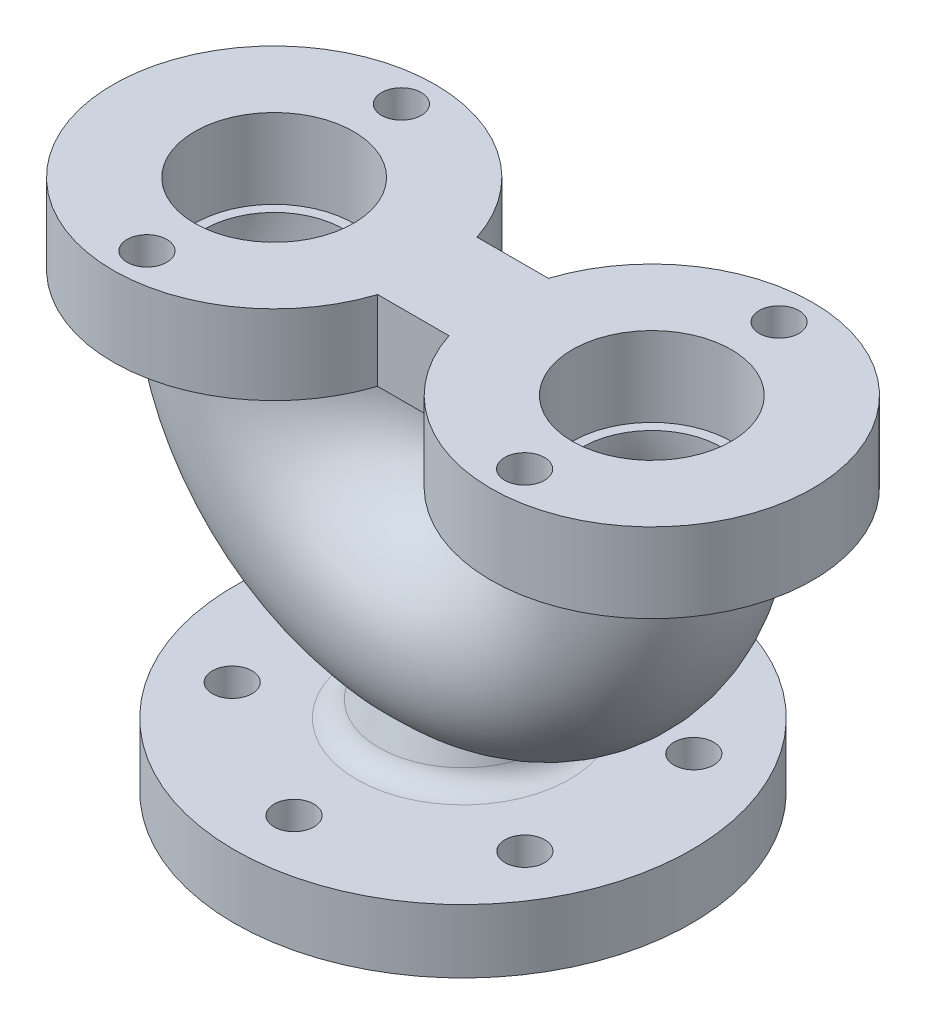
from build123d import *
from build123d.topology import SkipClean

# Parameters (mm, degrees)
SKETCH1_R           = 9.999999999999991
SKETCH1_R_2         = 10.000000000000009
BOSS_EXTRUDE1_DEPTH = 32
REVOLVE1_ANGLE      = 180.0000000000004
FILLET1_R           = 12
SKETCH4_R           = 50.000000000000014
SKETCH4_R_2         = 35.00000000000001
SKETCH7_R           = 40.00000000000001
BOSS_EXTRUDE2_DEPTH = 40
SKETCH9_R           = 9.999999999999996
SKETCH9_R_2         = 9.999999999999995
CUT_EXTRUDE1_DEPTH  = 40


with BuildPart() as part:
    # Sketch1 → Boss-Extrude1 (new body)
    with BuildSketch(Plane(origin=(0, 0, 0), x_dir=(1, 0, 0), z_dir=(0, 1, 0))):
        with BuildLine():
            Line((0, 20), (0, 0))
            ThreePointArc((4.961e-14, -1.421e-14), (115.00000000000001, 115.00000000000001), (0, 230))
            Line((0, 229.99999999999997), (0, 209.99999999999997))
            ThreePointArc((3.4e-16, 209.99999999999997), (10.000000000000608, 199.99999999999994), (0, 189.99999999999991))
            Line((0, 189.99999999999991), (0, 40))
            ThreePointArc((3.4e-16, 40), (10.000000000000004, 30), (0, 20))
        make_face()
        with Locations(Location((73.61215932167678, 72.49999999999912, 0), (0, 0, 270))):
            Circle(SKETCH1_R, mode=Mode.SUBTRACT)
        with Locations(Location((73.61215932167762, 157.49999999999926, 0), (0, 0, 270))):
            Circle(SKETCH1_R_2, mode=Mode.SUBTRACT)
    extrude(amount=BOSS_EXTRUDE1_DEPTH)

    # Sketch2 → Revolve1 (revolve)
    with BuildSketch(Plane.ZY):
        with BuildLine():
            Line((-159.99999999999997, 32), (-150.7871200772035, 32))
            Line((-150.78712007720353, 32), (-148.67529457169178, 48.040907268849466))
            ThreePointArc((-148.67529457169178, 48.040907268849466), (-150.92233750248081, 50.22090184668588), (-153.02854219188197, 52.53725244591505))
            Line((-153.028542191882, 52.537252445915016), (-159.99999999999997, 32))
        make_face()
    revolve(axis=Axis((0, 0, -114.99999999999996), (0, -1, 0)), revolution_arc=REVOLVE1_ANGLE)

    # Fillet1
    fillet1_edges = [part.edges().sort_by_distance(p)[0] for p in [
        (45.000000000000014, 32, -114.9999999999998),
    ]]
    fillet(fillet1_edges, radius=FILLET1_R)

    # Sketch2_6 → Cut-Revolve1 (revolve, cut)
    with BuildSketch(Plane.ZY):
        Polygon((-114.99999999999996, 0), (-114.99999999999996, 32), (-150.7871200772035, 32), (-154.99999999999997, 0), align=None)
    revolve(axis=Axis((0, 0, -114.99999999999996), (0, 1, 0)), mode=Mode.SUBTRACT)

    # Sweep1: sweep along a path in Sketch3
    with BuildLine(Plane.XY.offset(-114.99999999999996)) as sweep1_path:
        ThreePointArc((0, 84.99999999999999), (67.17514421272203, 112.82485578727798), (95, 180))
    # Sketch4 → Sweep1 (sweep)
    with BuildSketch(Plane(origin=(0, 180, 0), x_dir=(1, 0, 0), z_dir=(0, 1, 0))):
        with Locations((95, 114.99999999999996)):
            Circle(SKETCH4_R)
        with Locations((95, 114.99999999999996)):
            Circle(SKETCH4_R_2, mode=Mode.SUBTRACT)
    sweep(path=sweep1_path.line)

    # Sketch6 → Cut-Revolve2 (revolve, cut)
    with BuildSketch(Plane(origin=(0, 0, 0), x_dir=(0, 0, -1), z_dir=(1, 0, 0))):
        with BuildLine():
            Line((114.99999999999996, 0), (154.99999999999997, 0))
            Line((154.99999999999997, 0), (145.9589236730641, 68.67379269378867))
            ThreePointArc((145.9589236730641, 68.67379269378867), (133.07737182616157, 55.02987107370576), (114.99999999999996, 50))
            Line((114.99999999999996, 50), (114.99999999999996, 0))
        make_face()
    revolve(axis=Axis((0, 0, -114.99999999999996), (0, 1, 0)), mode=Mode.SUBTRACT)

    # Mirror1 2: part across plane


with BuildPart() as body_2:
    # Sketch7 → Boss-Extrude2 (new body)
    with BuildSketch(Plane(origin=(0, 180, 0), x_dir=(1, 0, 0), z_dir=(0, 1, 0))):
        with BuildLine():
            Line((17.954558862967108, 139.99999999999997), (8.2e-16, 139.99999999999997))
            Line((8.2e-16, 139.99999999999997), (6.94e-15, 89.99999999999996))
            Line((6.94e-15, 89.99999999999996), (17.954558862967115, 89.99999999999994))
            ThreePointArc((17.954558862967115, 89.99999999999994), (176, 114.99999999999996), (17.954558862967108, 139.99999999999997))
        make_face()
        with Locations(Location((95, 114.99999999999996, 0), (0, 0, 270))):
            Circle(SKETCH7_R, mode=Mode.SUBTRACT)
    extrude(amount=BOSS_EXTRUDE2_DEPTH)

    # Sketch9 → Cut-Extrude1 (cut)
    with BuildSketch(Plane(origin=(0, 220, 0), x_dir=(1, 0, 0), z_dir=(0, 1, 0))):
        with Locations(Location((94.99999999999999, 178.99999999999997, 0), (0, 0, 270))):
            Circle(SKETCH9_R)
        with Locations(Location((94.99999999999999, 50.999999999999964, 0), (0, 0, 270))):
            Circle(SKETCH9_R_2)
    extrude(amount=-CUT_EXTRUDE1_DEPTH, mode=Mode.SUBTRACT)

    # Mirror1: body 2 across plane


with BuildPart() as body_2_1:
    add(body_2.part)
    add(body_2.part.mirror(Plane(origin=(0, 32, 0), x_dir=(0, 0, 1), z_dir=(-1, 0, 0))))


with BuildPart() as part_1:
    with SkipClean():  # the faces are left unmerged after this step: merging them gives an invalid solid
        add(part.part)
        add(part.part.mirror(Plane(origin=(0, 32, 0), x_dir=(0, 0, 1), z_dir=(-1, 0, 0))))


solid = Compound([body_2_1.part, part_1.part])
